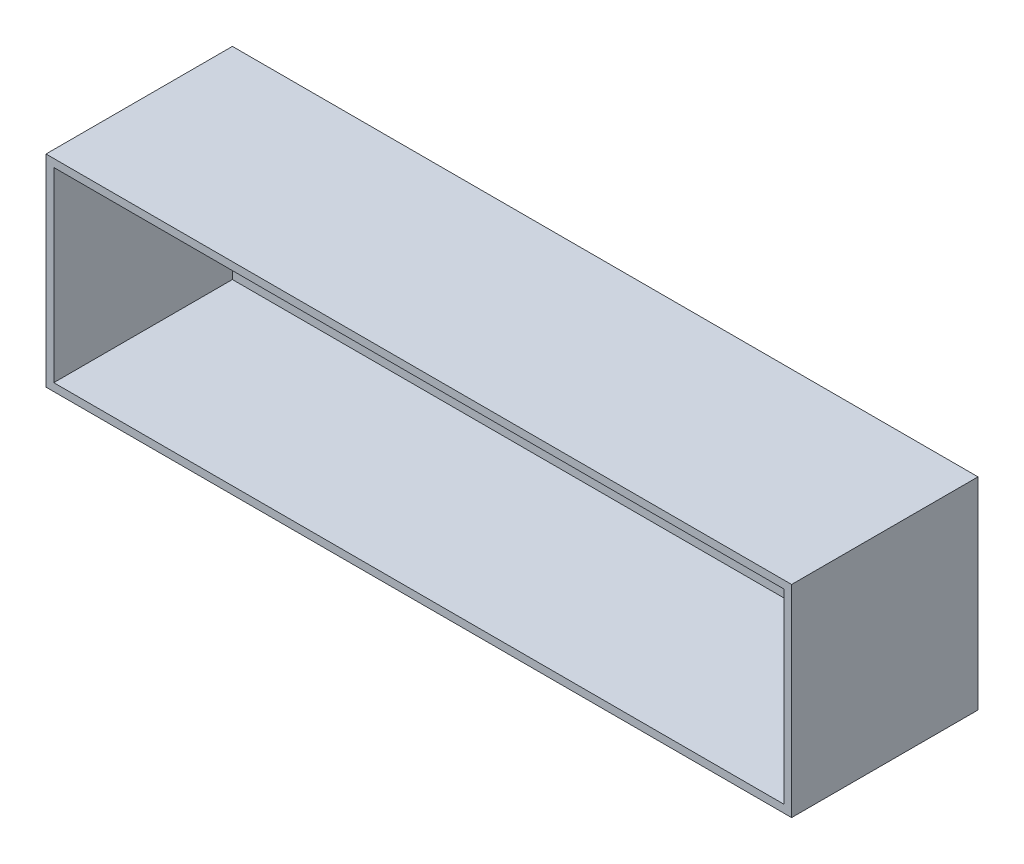
from build123d import *

# Parameters (mm, degrees)
SKETCH1_W           = 609.6
SKETCH1_H           = 165.1
BOSS_EXTRUDE1_DEPTH = 152.4
SHELL1_T            = -6.35
SKETCH4_W           = 114.3
SKETCH4_H           = 76.2
CUT_EXTRUDE1_DEPTH  = 6.35


with BuildPart() as part:
    # Sketch1 → Boss-Extrude1 (new body)
    with BuildSketch(Plane.XY):
        with Locations((0, 82.55)):
            Rectangle(SKETCH1_W, SKETCH1_H)
    extrude(amount=-BOSS_EXTRUDE1_DEPTH)

    # Shell1
    shell1_openings = [part.faces().sort_by_distance(p)[0] for p in [
        (0, 82.55, 0),
    ]]
    offset(amount=SHELL1_T, openings=shell1_openings, kind=Kind.INTERSECTION)

    # Sketch4 → Cut-Extrude1 (cut)
    with BuildSketch(Plane(origin=(0, 0, -152.4), x_dir=(-1, 0, 0), z_dir=(0, 0, -1))):
        with Locations((-241.3, 44.45)):
            Rectangle(SKETCH4_W, SKETCH4_H)
    extrude(amount=-CUT_EXTRUDE1_DEPTH, mode=Mode.SUBTRACT)


solid = part.part
